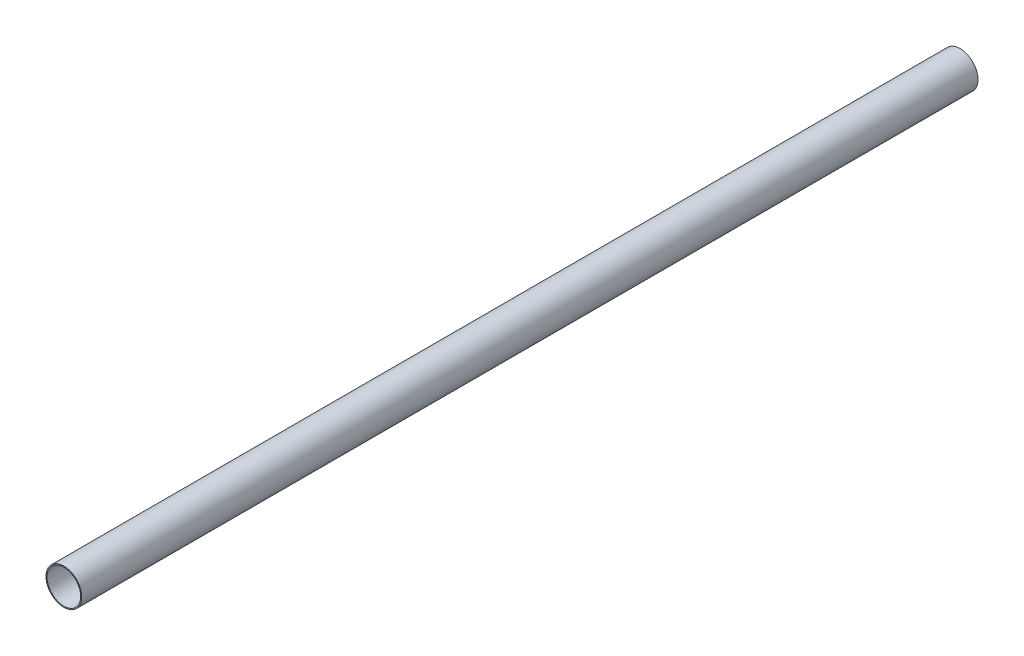
from build123d import *

# Parameters (mm, degrees)
PIPESKETCH_R    = 109.474
PIPESKETCH_R_2  = 103.124
EXTRUSION_DEPTH = 5486.4


with BuildPart() as part:
    # PipeSketch → Extrusion (new body)
    with BuildSketch(Plane.XY):
        Circle(PIPESKETCH_R)
        Circle(PIPESKETCH_R_2, mode=Mode.SUBTRACT)
    extrude(amount=EXTRUSION_DEPTH)


solid = part.part
